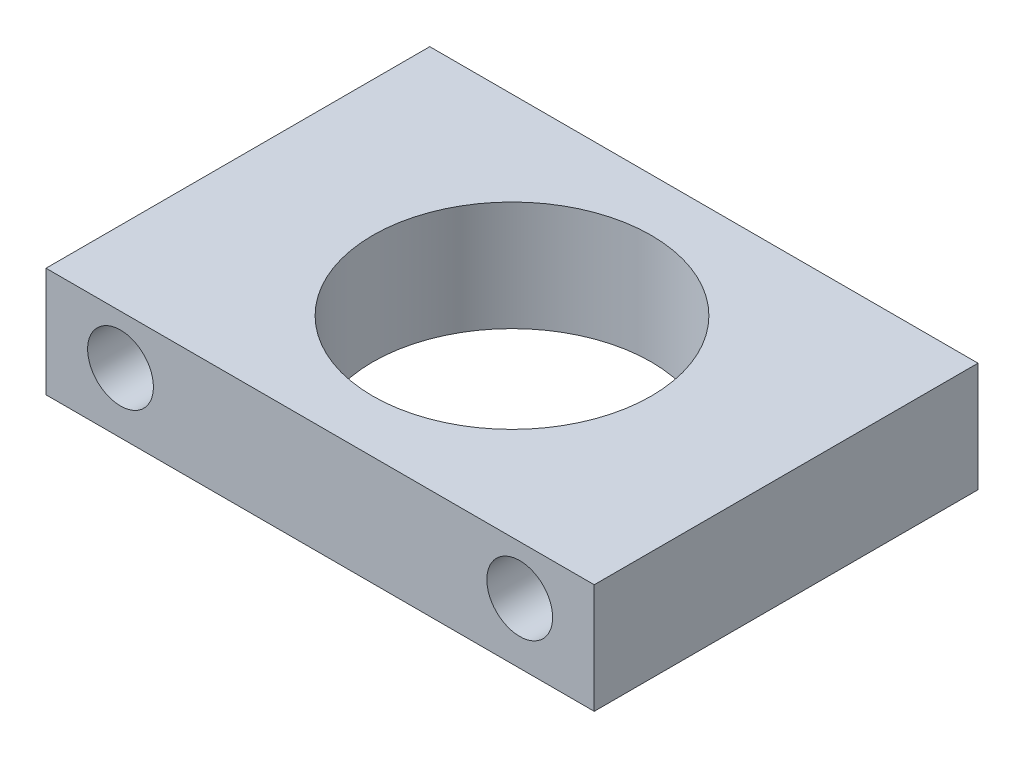
from build123d import *

# Parameters (mm, degrees)
SKETCH1_W           = 50
SKETCH1_H           = 35
SKETCH1_R           = 12.7
BOSS_EXTRUDE1_DEPTH = 10
SKETCH2_R           = 3
CUT_EXTRUDE1_DEPTH  = 62


with BuildPart() as part:
    # Sketch1 → Boss-Extrude1 (new body)
    with BuildSketch(Plane(origin=(0, 0, 0), x_dir=(1, 0, 0), z_dir=(0, 1, 0))):
        Rectangle(SKETCH1_W, SKETCH1_H)
        Circle(SKETCH1_R, mode=Mode.SUBTRACT)
    extrude(amount=BOSS_EXTRUDE1_DEPTH)

    # Sketch2 → Cut-Extrude1 (cut)
    with BuildSketch(Plane.XY.offset(17.5)):
        with Locations((-18.20341196, 5.515881638)):
            Circle(SKETCH2_R)
        with Locations((18.20341196, 5.515881638)):
            Circle(SKETCH2_R)
    extrude(amount=-CUT_EXTRUDE1_DEPTH, mode=Mode.SUBTRACT)


solid = part.part
